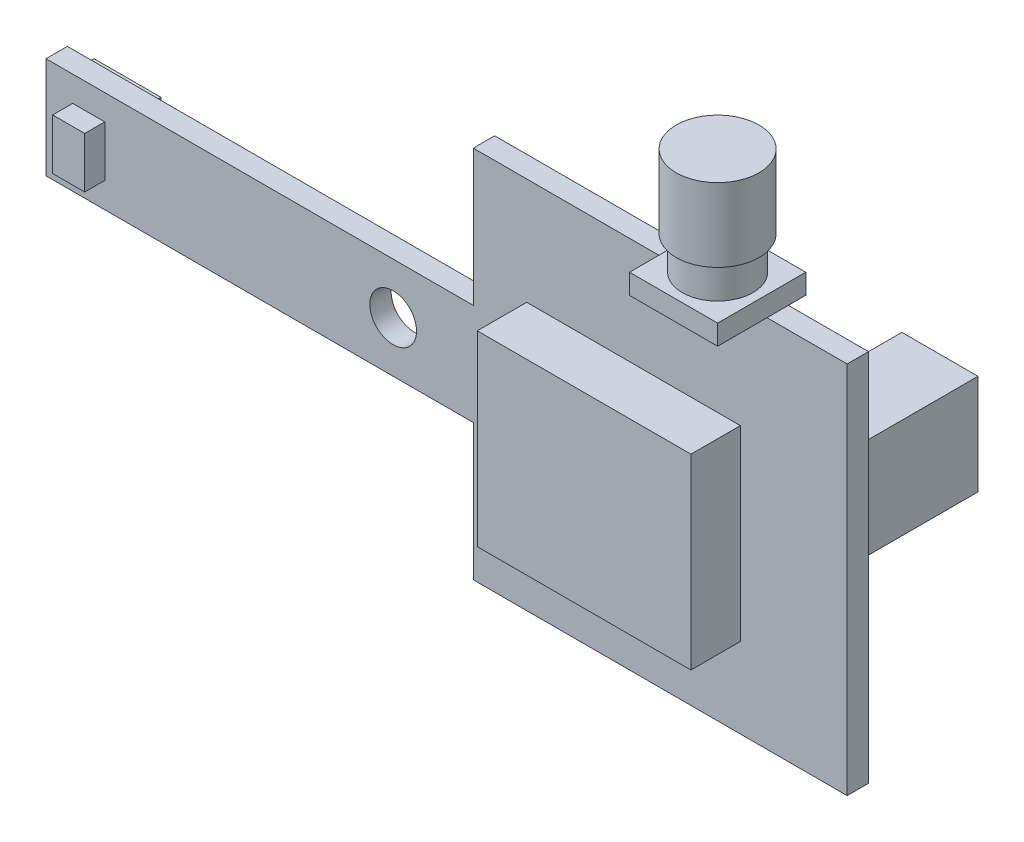
from build123d import *

# Parameters (mm, degrees)
SKETCH1_W             = 28
SKETCH1_H             = 28
SKETCH1_W_2           = 32
SKETCH1_H_2           = 7.6
SKETCH1_R             = 1.75
BOSS_EXTRUDE1_DEPTH   = 1.6
SKETCH2_W             = 6.6
SKETCH2_H             = 6.6
BOSS_EXTRUDE2_DEPTH   = 1.5
SKETCH3_R             = 2.65
BOSS_EXTRUDE3_DEPTH   = 2.5
SKETCH4_R             = 3.1
BOSS_EXTRUDE4_DEPTH   = 5.5
SKETCH5_W             = 16
SKETCH5_H             = 14
BOSS_EXTRUDE5_DEPTH   = 3.7
SKETCH6_W             = 2.4
SKETCH6_H             = 3.8
BOSS_EXTRUDE6_DEPTH   = 1.5
SKETCH7_W             = 5.7
SKETCH7_H             = 7.5
BOSS_EXTRUDE7_DEPTH   = 1.5
SKETCH7_W_2           = 7.3
SKETCH7_H_2           = 6.8
BOSS_EXTRUDE7_2_DEPTH = 1.5
SKETCH7_W_3           = 5
SKETCH7_H_3           = 5
BOSS_EXTRUDE7_3_DEPTH = 1.5
MOVE_FACE2_BY         = 8


with BuildPart() as part:
    # Sketch1 → Boss-Extrude1 (new body)
    with BuildSketch(Plane.XY):
        with Locations((14, 0)):
            Rectangle(SKETCH1_W, SKETCH1_H)
        with Locations((-16, 0)):
            Rectangle(SKETCH1_W_2, SKETCH1_H_2)
        with Locations((-6, 0)):
            Circle(SKETCH1_R, mode=Mode.SUBTRACT)
    extrude(amount=BOSS_EXTRUDE1_DEPTH)


with BuildPart() as body_2:
    # Sketch2 → Boss-Extrude2 (new body)
    with BuildSketch(Plane(origin=(0, 14, 0), x_dir=(1, 0, 0), z_dir=(0, 1, 0))):
        with Locations((18.7, -2)):
            Rectangle(SKETCH2_W, SKETCH2_H)
    extrude(amount=BOSS_EXTRUDE2_DEPTH)

    # Sketch3 → Boss-Extrude3 (add)
    with BuildSketch(Plane(origin=(0, 15.5, 0), x_dir=(1, 0, 0), z_dir=(0, 1, 0))):
        with Locations(Location((18.7, -2, 0), (0, 0, 270))):
            Circle(SKETCH3_R)
    extrude(amount=BOSS_EXTRUDE3_DEPTH)

    # Sketch4 → Boss-Extrude4 (add)
    with BuildSketch(Plane(origin=(0, 18, 0), x_dir=(1, 0, 0), z_dir=(0, 1, 0))):
        with Locations(Location((18.7, -2, 0), (0, 0, 270))):
            Circle(SKETCH4_R)
    extrude(amount=BOSS_EXTRUDE4_DEPTH)


with BuildPart() as body_3:
    # Sketch5 → Boss-Extrude5 (new body)
    with BuildSketch(Plane.XY.offset(1.6)):
        with Locations((12, -1)):
            Rectangle(SKETCH5_W, SKETCH5_H)
    extrude(amount=BOSS_EXTRUDE5_DEPTH)


with BuildPart() as body_4:
    # Sketch6 → Boss-Extrude6 (new body)
    with BuildSketch(Plane.XY.offset(1.6)):
        with Locations((-28.8, 0)):
            Rectangle(SKETCH6_W, SKETCH6_H)
    extrude(amount=BOSS_EXTRUDE6_DEPTH)


with BuildPart() as body_5:
    # Sketch7 → Boss-Extrude7 (new body)
    with BuildSketch(Plane(origin=(0, 0, 0), x_dir=(-1, 0, 0), z_dir=(0, 0, -1))):
        with Locations((-23.85, 3.25)):
            Rectangle(SKETCH7_W, SKETCH7_H)
    extrude(amount=BOSS_EXTRUDE7_DEPTH)

    # Move Face2: a face moved outward by 8.0
    extrude(body_5.faces().sort_by_distance((23.85, 3.25, -1.5))[0], amount=MOVE_FACE2_BY, dir=(0, 0, -1))


with BuildPart() as body_6:
    # Sketch7 → Boss-Extrude7 2 (new body)
    with BuildSketch(Plane(origin=(0, 0, 0), x_dir=(-1, 0, 0), z_dir=(0, 0, -1))):
        with Locations((-9.05, -0.6)):
            Rectangle(SKETCH7_W_2, SKETCH7_H_2)
    extrude(amount=BOSS_EXTRUDE7_2_DEPTH)


with BuildPart() as body_7:
    # Sketch7 → Boss-Extrude7 3 (new body)
    with BuildSketch(Plane(origin=(0, 0, 0), x_dir=(-1, 0, 0), z_dir=(0, 0, -1))):
        with Locations((29, 0)):
            Rectangle(SKETCH7_W_3, SKETCH7_H_3)
    extrude(amount=BOSS_EXTRUDE7_3_DEPTH)


solid = Compound([part.part, body_2.part, body_3.part, body_4.part, body_5.part, body_6.part, body_7.part])
